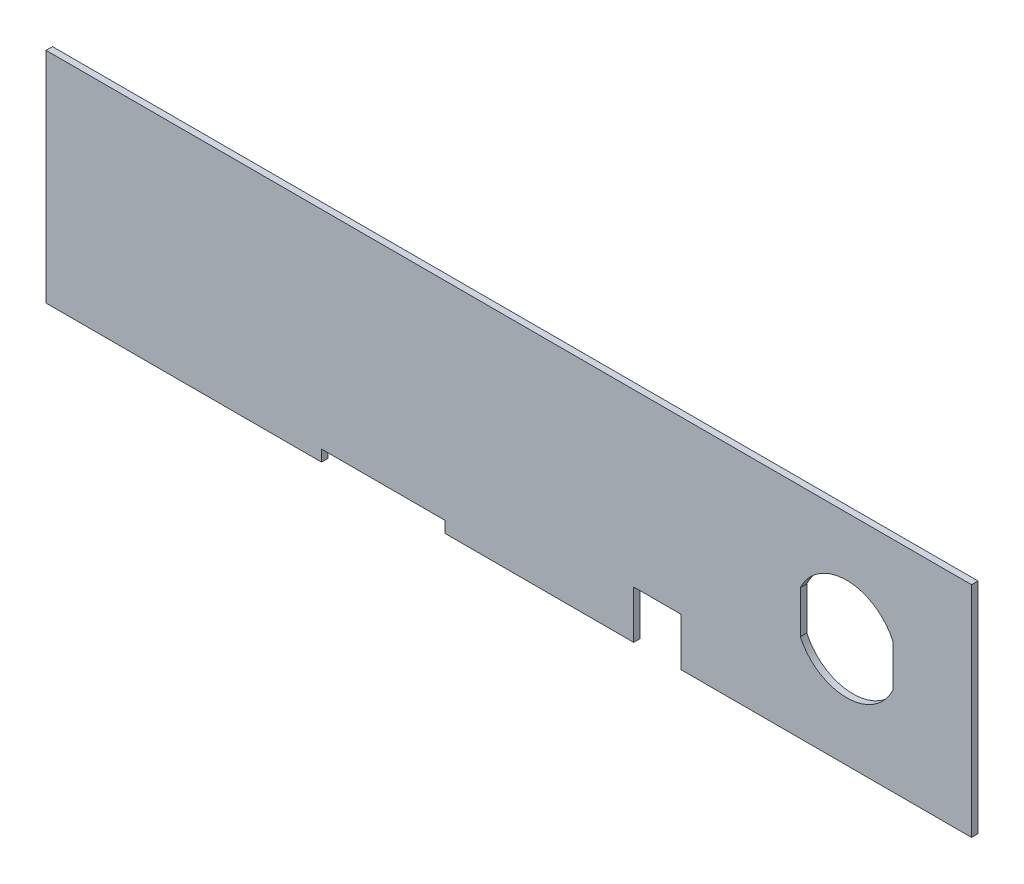
from build123d import *

# Parameters (mm, degrees)
BOSS_EXTRUDE2_DEPTH = 1.778


with BuildPart() as part:
    # Sketch1 → Boss-Extrude2 (new body)
    with BuildSketch(Plane.XY):
        Polygon((109.4486, 0), (161.29, 0), (161.29, 13.1699), (174.3202, 13.1699), (174.3202, 0), (254, 0), (254, 60.071), (0, 60.071), (0, 0), (75.6158, 0), (75.6158, 3.1115), (109.4486, 3.1115), align=None)
        with BuildLine():
            Line((232.41, 35.855371133), (232.41, 24.215628867))
            ThreePointArc((232.41, 24.215628867), (219.71, 16.0655), (207.01, 24.215628867))
            Line((207.01, 24.215628867), (207.01, 35.855371133))
            ThreePointArc((207.01, 35.855371133), (219.71, 44.0055), (232.41, 35.855371133))
        make_face(mode=Mode.SUBTRACT)
    extrude(amount=BOSS_EXTRUDE2_DEPTH)


solid = part.part
